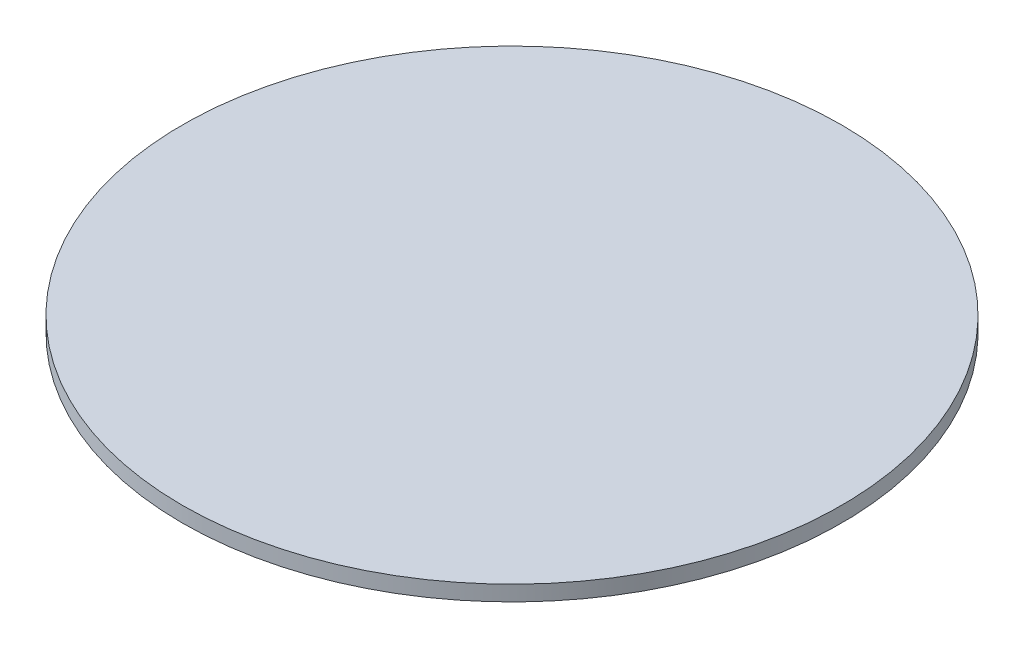
from build123d import *

# Parameters (mm, degrees)
SKETCH2_R           = 150
BOSS_EXTRUDE8_DEPTH = 7


with BuildPart() as part:
    # Sketch2 → Boss-Extrude8 (new body)
    with BuildSketch(Plane(origin=(0, 0, 0), x_dir=(1, 0, 0), z_dir=(0, 1, 0))):
        Circle(SKETCH2_R)
    extrude(amount=BOSS_EXTRUDE8_DEPTH)


solid = part.part
